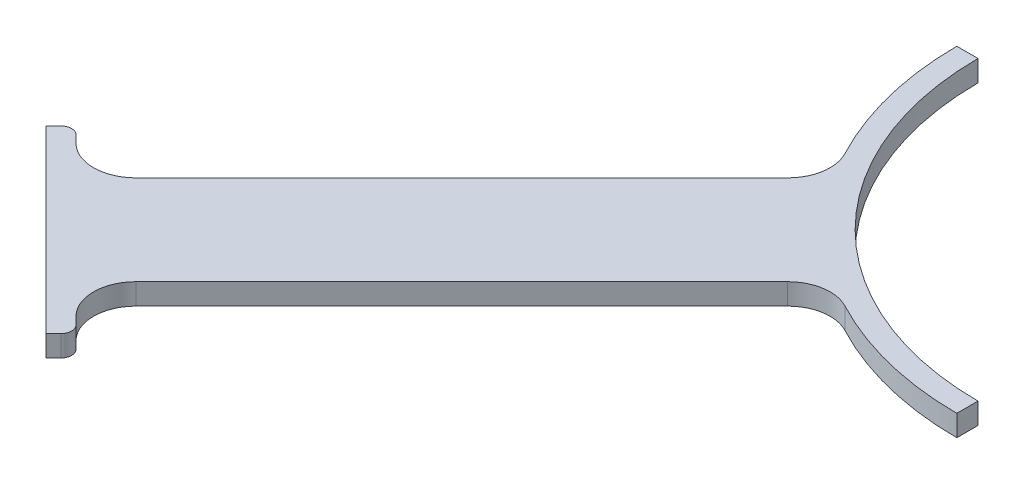
from build123d import *

# Parameters (mm, degrees)
BOSS_EXTRUDE1_DEPTH = 5
FILLET1_R           = 10
FILLET2_R           = 2.5


with BuildPart() as part:
    # Sketch2 → Boss-Extrude1 (new body)
    with BuildSketch(Plane(origin=(0, 0, 0), x_dir=(1, 0, 0), z_dir=(0, 1, 0))):
        with BuildLine():
            Line((-70, 0), (-75, 0))
            ThreePointArc((-75, 0), (-53.033008589, -53.033008589), (0, -75))
            Line((0, -75), (0, -70))
            ThreePointArc((0, -70), (-49.497474683, -49.497474683), (-70, 0))
        make_face()
        with BuildLine():
            ThreePointArc((-41.354922509, -62.568125945), (-53.033008589, -53.033008589), (-62.568125945, -41.354922509))
            Line((-62.568125945, -41.354922509), (-152.027957955, -130.81475452))
            Line((-152.027957955, -130.81475452), (-162.634559673, -120.208152802))
            Line((-162.634559673, -120.208152802), (-166.170093579, -123.743686708))
            Line((-166.170093579, -123.743686708), (-144.956890143, -144.956890143))
            Line((-144.956890143, -144.956890143), (-123.743686708, -166.170093579))
            Line((-123.743686708, -166.170093579), (-120.208152802, -162.634559673))
            Line((-120.208152802, -162.634559673), (-130.81475452, -152.027957955))
            Line((-130.81475452, -152.027957955), (-41.354922509, -62.568125945))
        make_face()
    extrude(amount=BOSS_EXTRUDE1_DEPTH)

    # Fillet1
    fillet1_edges = [part.edges().sort_by_distance(p)[0] for p in [
        (-41.354922509, 2.5, 62.568125945),
        (-130.81475452, 2.5, 152.027957955),
        (-152.027957955, 2.5, 130.81475452),
        (-62.568125945, 2.5, 41.354922509),
    ]]
    fillet(fillet1_edges, radius=FILLET1_R)

    # Fillet2
    fillet2_edges = [part.edges().sort_by_distance(p)[0] for p in [
        (-120.208152802, 2.5, 162.634559673),
        (-162.634559673, 2.5, 120.208152802),
    ]]
    fillet(fillet2_edges, radius=FILLET2_R)


solid = part.part
